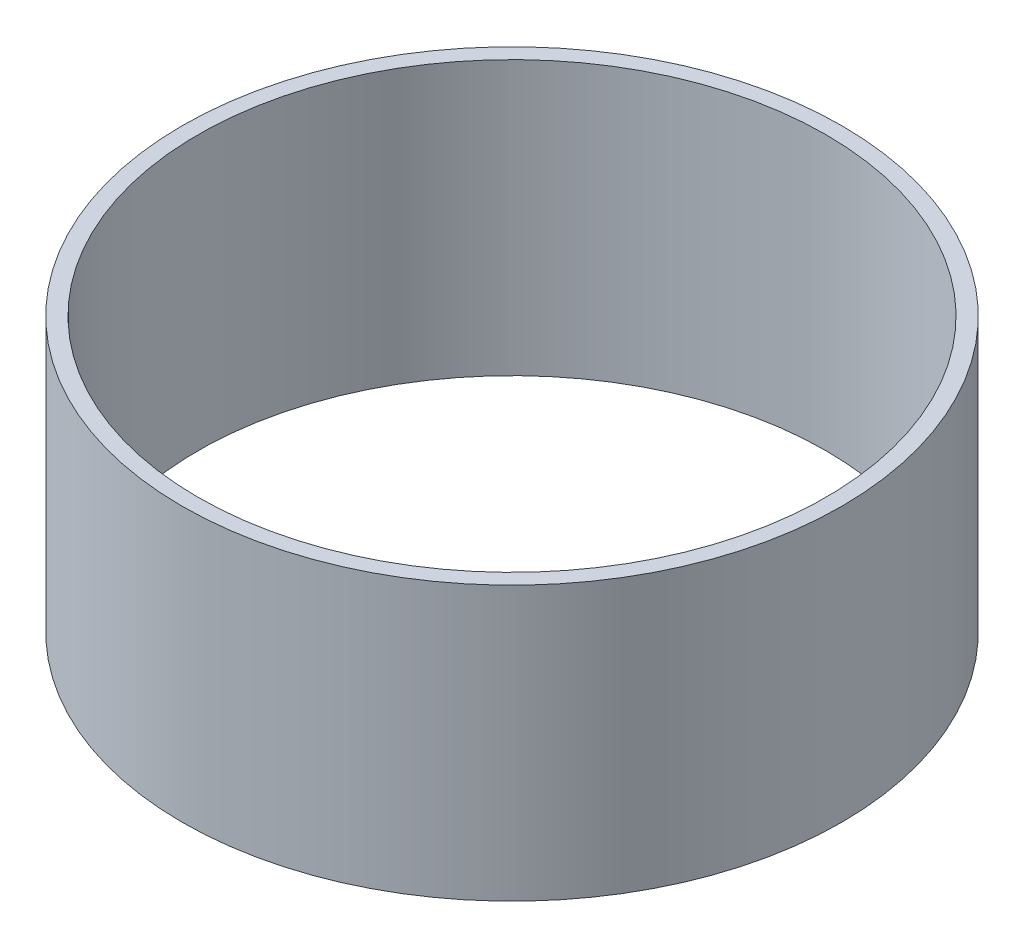
from build123d import *

# Parameters (mm, degrees)
SKETCH_1_R          = 63
EXTRUDE_1_DEPTH     = 52.3
SKETCH_2_R          = 60
CUT_EXTRUDE_1_DEPTH = 52.3


with BuildPart() as part:
    # Эскиз1 → Бобышка-Вытянуть1 (new body)
    with BuildSketch(Plane(origin=(0, 0, 0), x_dir=(1, 0, 0), z_dir=(0, 1, 0))):
        Circle(SKETCH_1_R)
    extrude(amount=EXTRUDE_1_DEPTH)

    # Эскиз2 → Вырез-Вытянуть1 (cut)
    with BuildSketch(Plane(origin=(0, 52.3, 0), x_dir=(1, 0, 0), z_dir=(0, 1, 0))):
        Circle(SKETCH_2_R)
    extrude(amount=-CUT_EXTRUDE_1_DEPTH, mode=Mode.SUBTRACT)


solid = part.part
